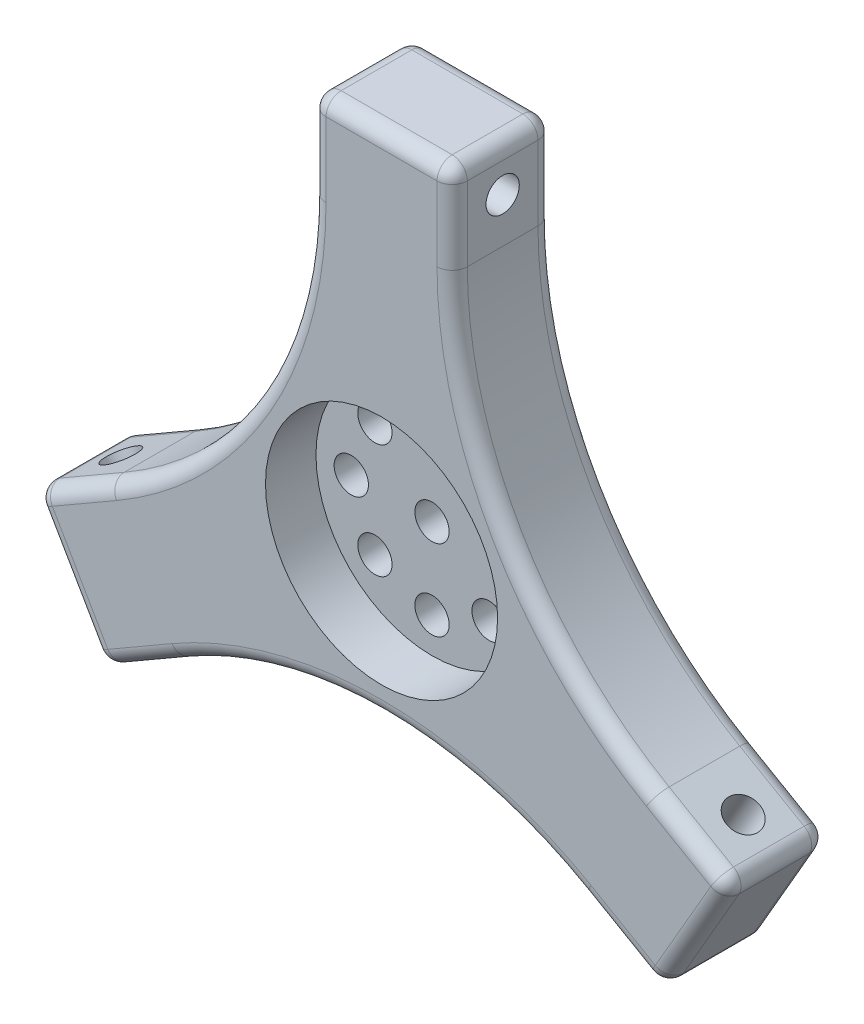
from build123d import *

# Parameters (mm, degrees)
BOSS_EXTRUDE1_DEPTH       = 10
FILLET1_R                 = 40
M4X0_7_TAPPED_HOLE1_D     = 3.3
M4X0_7_TAPPED_HOLE1_DEPTH = 17.839823294
M3_CLEARANCE_HOLE3_D      = 3.4
M3_CLEARANCE_HOLE3_DEPTH  = 10
SKETCH23_R                = 11.5
CUT_EXTRUDE3_DEPTH        = 5
CIRPATTERN2_COUNT         = 3
FILLET2_R                 = 1.5


with BuildPart() as part:
    # Sketch1 → Boss-Extrude1 (new body)
    with BuildSketch(Plane.XY):
        Polygon((7, 36), (-7, 36), (-7, 4.041451884), (-34.676914536, -11.937822174), (-27.676914536, -24.062177826), (0, -8.082903769), (27.676914536, -24.062177826), (34.676914536, -11.937822174), (7, 4.041451884), align=None)
    extrude(amount=BOSS_EXTRUDE1_DEPTH)

    # Fillet1
    fillet1_edges = [part.edges().sort_by_distance(p)[0] for p in [
        (7, 4.041451884, 5),
        (0, -8.082903769, 5),
        (-7, 4.041451884, 5),
    ]]
    fillet(fillet1_edges, radius=FILLET1_R)

    # M4x0.7 Tapped Hole1
    with Locations(Plane.ZY.offset(7)):
        with Locations((5, 31.567731326)):
            m4x0_7_tapped_hole1 = Hole(M4X0_7_TAPPED_HOLE1_D / 2, depth=M4X0_7_TAPPED_HOLE1_DEPTH)

    # M3 Clearance Hole3
    with Locations(Plane.XY.offset(10)):
        with Locations((0, 0), (0, 8), (5.656854249, 5.656854249), (8, 0), (5.656854249, -5.656854249), (0, -8), (-5.656854249, -5.656854249), (-8, 0), (-5.656854249, 5.656854249)):
            Hole(M3_CLEARANCE_HOLE3_D / 2, depth=M3_CLEARANCE_HOLE3_DEPTH)

    # Sketch23 → Cut-Extrude3 (cut)
    with BuildSketch(Plane.XY.offset(10)):
        Circle(SKETCH23_R)
    extrude(amount=-CUT_EXTRUDE3_DEPTH, mode=Mode.SUBTRACT)

    # CirPattern2: M4x0.7 Tapped Hole1 ×3 about axis
    cirpattern2_axis = Axis((0, 0, 5), (0, 0, 1))
    for i in range(1, CIRPATTERN2_COUNT):
        add(m4x0_7_tapped_hole1.rotate(cirpattern2_axis, i * 360 / CIRPATTERN2_COUNT), mode=Mode.SUBTRACT)

    # Fillet2
    fillet2_edges = [part.edges().sort_by_distance(p)[0] for p in [
        (30.838457268, -9.721687836, 0),
        (31.176914536, -18, 0),
        (-23.838457268, -21.846043489, 0),
        (-31.176914536, -18, 0),
        (-7, 31.567731326, 0),
        (-31.176914536, -18, 10),
        (-7, 36, 5),
        (7, 36, 5),
        (34.676914536, -11.937822174, 5),
        (27.676914536, -24.062177826, 5),
        (-27.676914536, -24.062177826, 5),
        (-34.676914536, -11.937822174, 5),
        (-23.838457268, -21.846043489, 10),
        (31.176914536, -18, 10),
        (23.838457268, -21.846043489, 0),
        (23.838457268, -21.846043489, 10),
        (30.838457268, -9.721687836, 10),
        (7, 31.567731326, 0),
        (7, 31.567731326, 10),
        (-30.838457268, -9.721687836, 0),
        (-30.838457268, -9.721687836, 10),
        (0, -14.270925304, 0),
        (0, -14.270925304, 10),
        (12.358983849, 7.135462652, 0),
        (12.358983849, 7.135462652, 10),
        (-12.358983849, 7.135462652, 0),
        (-12.358983849, 7.135462652, 10),
        (0, 36, 10),
        (-7, 31.567731326, 10),
        (0, 36, 0),
    ]]
    fillet(fillet2_edges, radius=FILLET2_R)


solid = part.part
